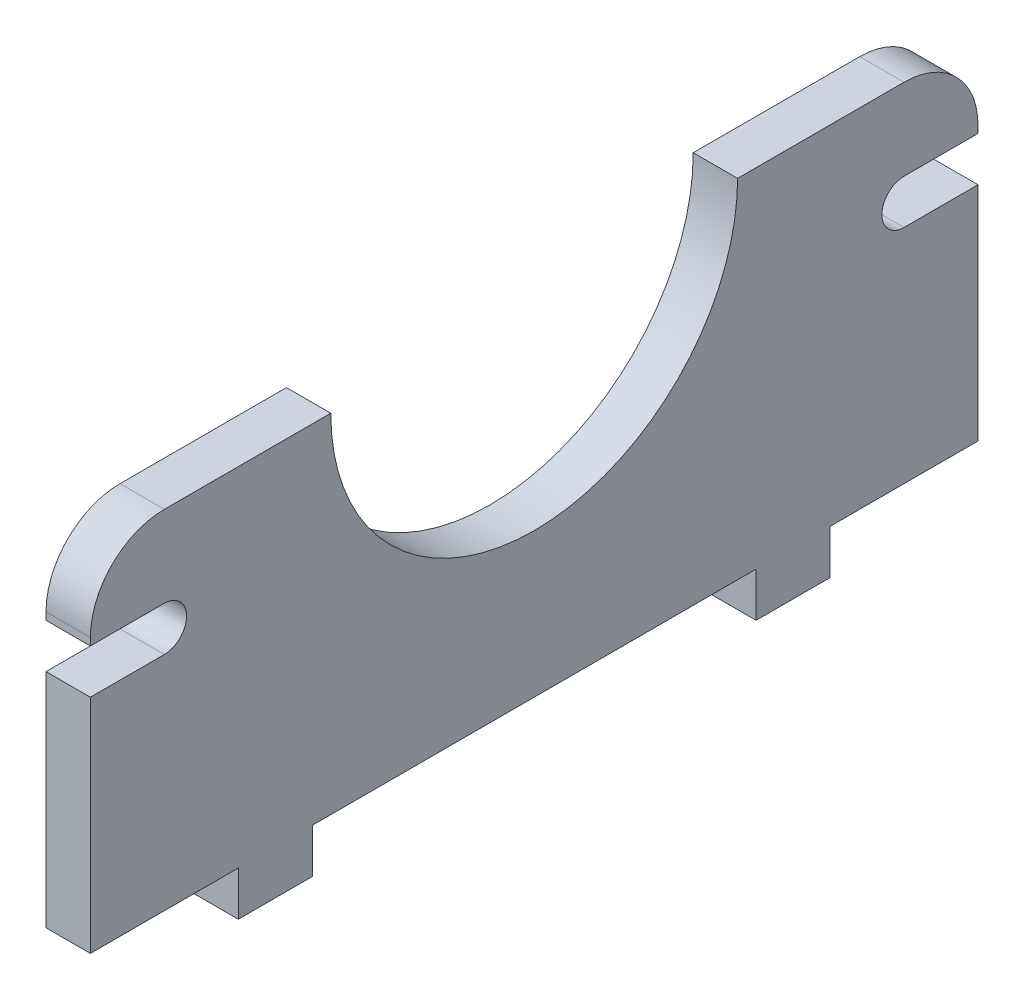
from build123d import *

# Parameters (mm, degrees)
BOSS_EXTRUDE1_DEPTH = 3
CUT_EXTRUDE1_DEPTH  = 4
FILLET1_R           = 5
SKETCH3_W           = 3
SKETCH3_H           = 5
BOSS_EXTRUDE2_DEPTH = 3


with BuildPart() as part:
    # Sketch1 → Boss-Extrude1 (new body)
    with BuildSketch(Plane(origin=(0, 0, 0), x_dir=(0, 0, -1), z_dir=(1, 0, 0))):
        with BuildLine():
            Line((-13.75, 11.75), (-30, 11.75))
            Line((-30, 11.75), (-30, -11.75))
            Line((-30, -11.75), (30, -11.75))
            Line((30, -11.75), (30, 11.75))
            Line((30, 11.75), (13.75, 11.75))
            ThreePointArc((13.75, 11.75), (0, -2), (-13.75, 11.75))
        make_face()
    extrude(amount=BOSS_EXTRUDE1_DEPTH)

    # Sketch2 → Cut-Extrude1 (cut, through all)
    with BuildSketch(Plane(origin=(3, 0, 0), x_dir=(0, 0, -1), z_dir=(1, 0, 0))):
        with BuildLine():
            Line((-25, 6.25), (-30, 6.25))
            Line((-30, 6.25), (-30, 3.25))
            Line((-30, 3.25), (-25, 3.25))
            ThreePointArc((-25, 3.25), (-23.5, 4.75), (-25, 6.25))
        make_face()
    cut_extrude1 = extrude(amount=-CUT_EXTRUDE1_DEPTH, mode=Mode.SUBTRACT)

    # Mirror2: Cut-Extrude1 across plane
    add(cut_extrude1.mirror(Plane.XY), mode=Mode.SUBTRACT)

    # Fillet1
    fillet1_edges = [part.edges().sort_by_distance(p)[0] for p in [
        (1.5, 11.75, 30),
        (1.5, 11.75, -30),
    ]]
    fillet(fillet1_edges, radius=FILLET1_R)

    # Sketch3 → Boss-Extrude2 (add)
    with BuildSketch(Plane.XZ.offset(11.75)):
        with Locations((1.5, 17.5)):
            Rectangle(SKETCH3_W, SKETCH3_H)
    boss_extrude2 = extrude(amount=BOSS_EXTRUDE2_DEPTH)

    # Mirror3: Boss-Extrude2 across plane
    add(boss_extrude2.mirror(Plane.XY))


solid = part.part
